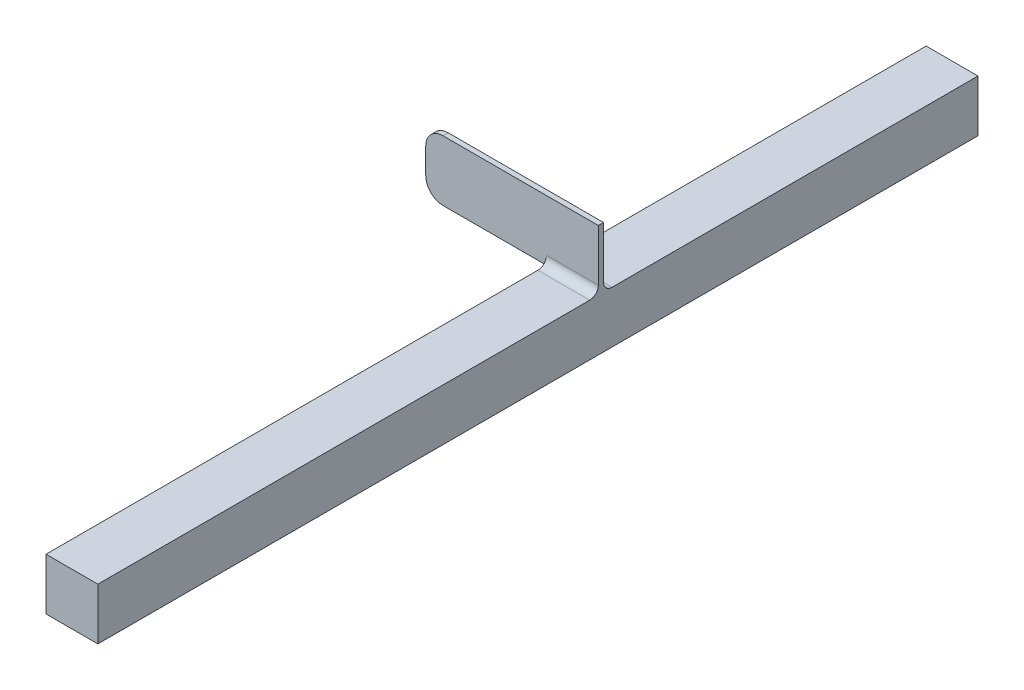
from build123d import *

# Parameters (mm, degrees)
ESBO_O2_W                     = 30.045415171
ESBO_O2_H                     = 30
RESSALTO_EXTRUS_O1_DEPTH      = 255
ESBO_O3_W                     = 100
ESBO_O3_H                     = 35
RESSALTO_EXTRUS_O2_DEPTH      = 0.001
RESSALTO_EXTRUS_O2_DEPTH_BACK = 3
FILETE1_R                     = 5
FILETE2_R                     = 10


with BuildPart() as part:
    # Esboço2 → Ressalto-extrusão1 (new body, symmetric)
    with BuildSketch(Plane.XY):
        with Locations((-95.635568537, 15)):
            Rectangle(ESBO_O2_W, ESBO_O2_H)
    extrude(amount=RESSALTO_EXTRUS_O1_DEPTH, both=True)

    # Esboço3 → Ressalto-extrusão2 (add, two sides)
    with BuildSketch(Plane.XY.offset(-35)) as ressalto_extrus_o2_sk:
        with Locations((-130.612860951, 47.5)):
            Rectangle(ESBO_O3_W, ESBO_O3_H)
    extrude(amount=RESSALTO_EXTRUS_O2_DEPTH)
    extrude(ressalto_extrus_o2_sk.sketch, amount=-RESSALTO_EXTRUS_O2_DEPTH_BACK)

    # Filete1
    filete1_edges = [part.edges().sort_by_distance(p)[0] for p in [
        (-95.635568536, 30, -38),
        (-95.635568536, 30, -34.999),
    ]]
    fillet(filete1_edges, radius=FILETE1_R)

    # Filete2
    filete2_edges = [part.edges().sort_by_distance(p)[0] for p in [
        (-180.612860951, 30, -36.4995),
        (-180.612860951, 65, -36.4995),
    ]]
    fillet(filete2_edges, radius=FILETE2_R)


solid = part.part
